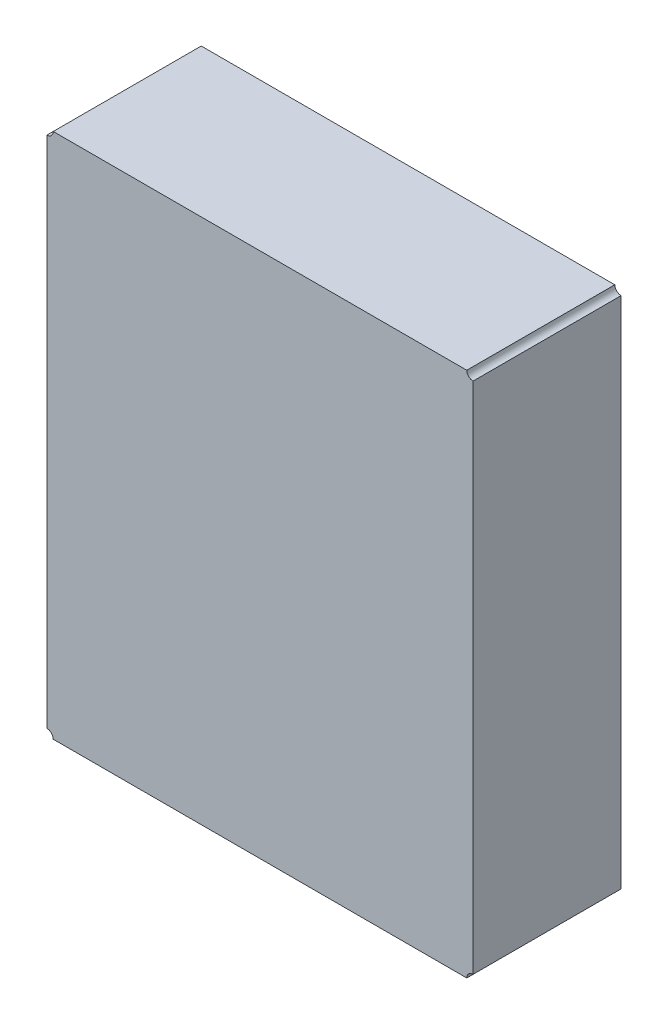
from build123d import *

# Parameters (mm, degrees)
EXTRUDE_1_DEPTH = 1.5


with BuildPart() as part:
    # 草图1 → 凸台-拉伸1 (new body)
    with BuildSketch(Plane.XY):
        with BuildLine():
            Line((90.932, 81.2165), (90.932, 76.0095))
            ThreePointArc((90.932, 76.0095), (90.976901281, 75.990901281), (90.9955, 75.946))
            Line((90.9955, 75.946), (95.1865, 75.946))
            ThreePointArc((95.1865, 75.946), (95.205098719, 75.990901281), (95.25, 76.0095))
            Line((95.25, 76.0095), (95.25, 81.2165))
            ThreePointArc((95.25, 81.2165), (95.205098719, 81.235098719), (95.1865, 81.28))
            Line((95.1865, 81.28), (90.9955, 81.28))
            ThreePointArc((90.9955, 81.28), (90.976901281, 81.235098719), (90.932, 81.2165))
        make_face()
    extrude(amount=EXTRUDE_1_DEPTH)


solid = part.part
